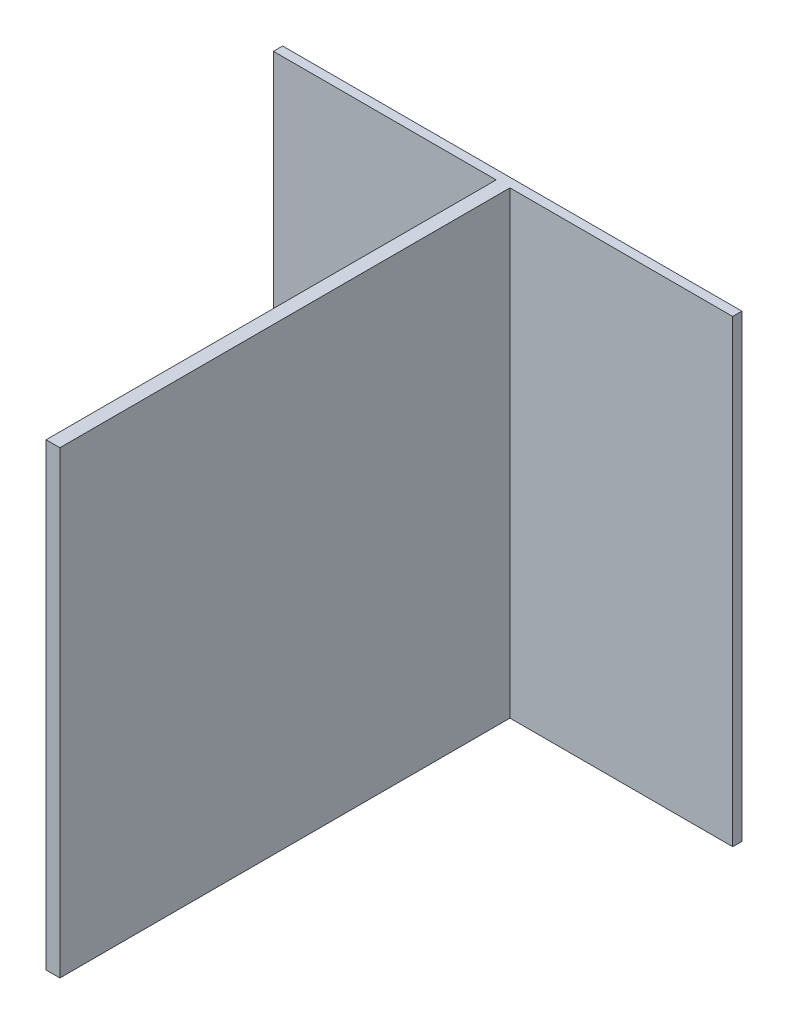
from build123d import *

# Parameters (mm, degrees)
SZKIC1_W                    = 100
SZKIC1_H                    = 100
DODANIE_WYCI_GNI_CIE1_DEPTH = 4
SZKIC2_W                    = 3
SZKIC2_H                    = 100
DODANIE_WYCI_GNI_CIE2_DEPTH = 196


with BuildPart() as part:
    # Szkic1 → Dodanie-wyciągnięcie1 (new body)
    with BuildSketch(Plane.XY):
        with Locations((-50, 50)):
            Rectangle(SZKIC1_W, SZKIC1_H)
        with Locations((50, 50)):
            Rectangle(SZKIC1_W, SZKIC1_H)
        with Locations((50, -50)):
            Rectangle(SZKIC1_W, SZKIC1_H)
        with Locations((-50, -50)):
            Rectangle(SZKIC1_W, SZKIC1_H)
    extrude(amount=DODANIE_WYCI_GNI_CIE1_DEPTH)

    # Szkic2 → Dodanie-wyciągnięcie2 (add)
    with BuildSketch(Plane.XY.offset(4)):
        with Locations((-1.5, 50)):
            Rectangle(SZKIC2_W, SZKIC2_H)
        with Locations((1.5, 50)):
            Rectangle(SZKIC2_W, SZKIC2_H)
        with Locations((-1.5, -50)):
            Rectangle(SZKIC2_W, SZKIC2_H)
        with Locations((1.5, -50)):
            Rectangle(SZKIC2_W, SZKIC2_H)
    extrude(amount=DODANIE_WYCI_GNI_CIE2_DEPTH)


solid = part.part
